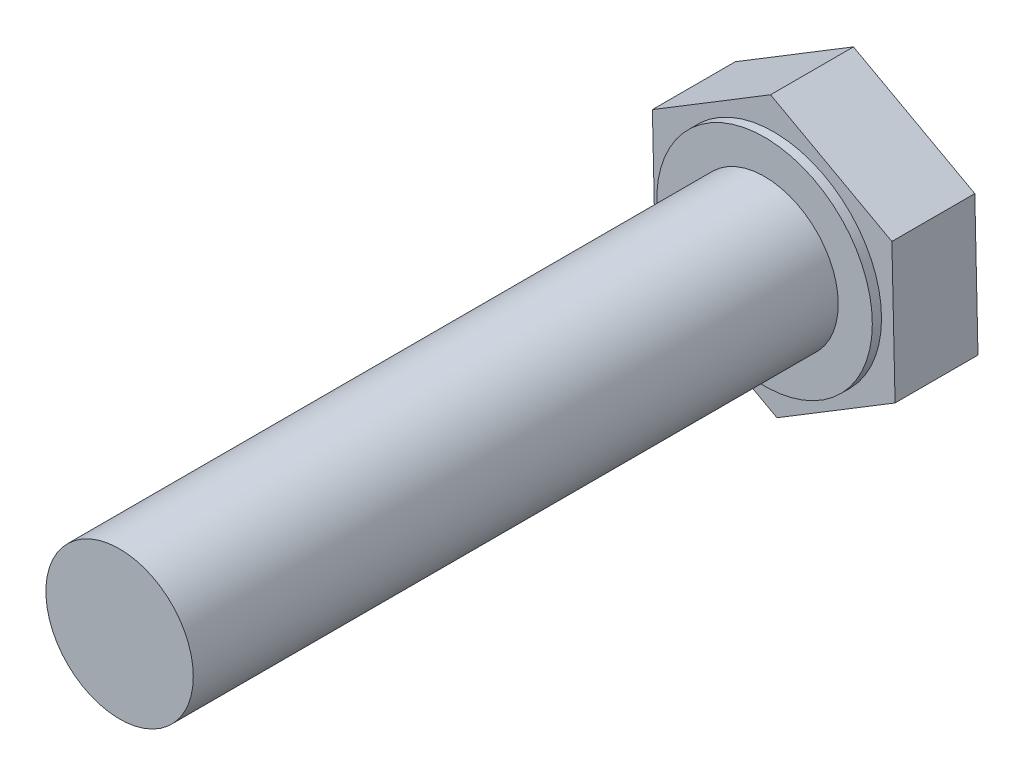
from build123d import *

# Parameters (mm, degrees)
BOSS_EXTRUDE1_DEPTH = 4.5
SKETCH2_R           = 5.85
BOSS_EXTRUDE2_DEPTH = 0.5
SKETCH3_R           = 4
BOSS_EXTRUDE3_DEPTH = 35


with BuildPart() as part:
    # Sketch1 → Boss-Extrude1 (new body)
    with BuildSketch(Plane.XY):
        Polygon((-6.411545587, -3.901975976), (0.173437527, -7.503549344), (6.584983114, -3.601573368), (6.411545587, 3.901975976), (-0.173437527, 7.503549344), (-6.584983114, 3.601573368), align=None)
    extrude(amount=BOSS_EXTRUDE1_DEPTH)

    # Sketch2 → Boss-Extrude2 (add)
    with BuildSketch(Plane.XY.offset(4.5)):
        Circle(SKETCH2_R)
    extrude(amount=BOSS_EXTRUDE2_DEPTH)

    # Sketch3 → Boss-Extrude3 (add)
    with BuildSketch(Plane.XY.offset(5)):
        Circle(SKETCH3_R)
    extrude(amount=BOSS_EXTRUDE3_DEPTH)


solid = part.part
